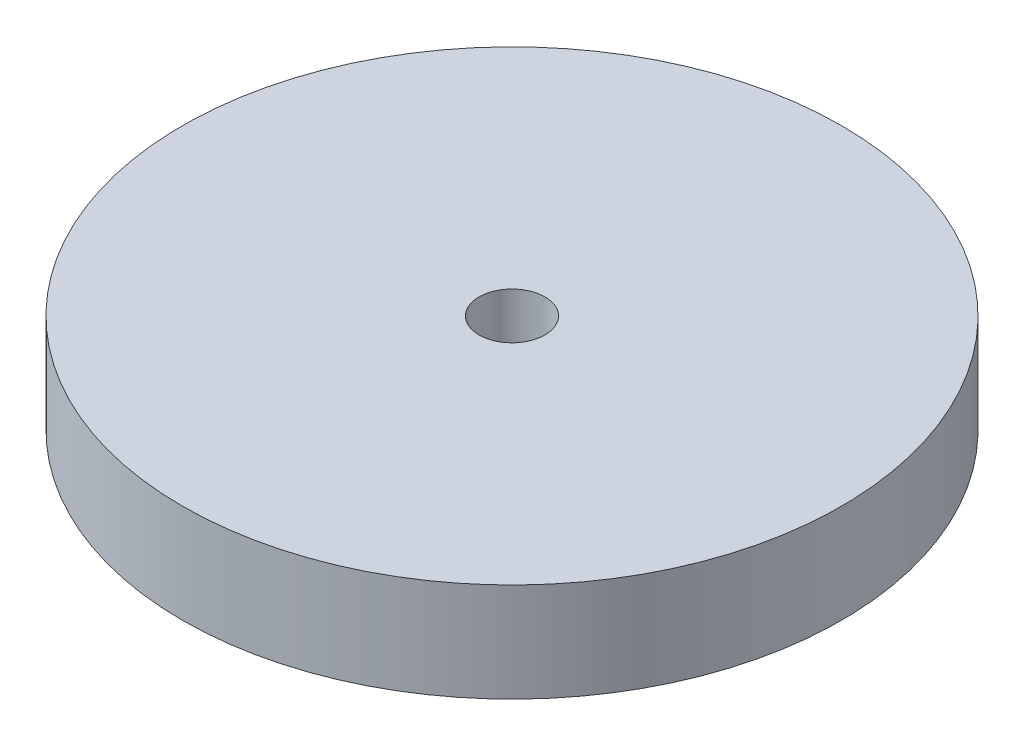
from build123d import *

# Parameters (mm, degrees)
BOSS_EXTRUDE1_DEPTH      = 7.5
BOSS_EXTRUDE1_DEPTH_BACK = 7.5
SKETCH1_R                = 50
CUT_EXTRUDE2_DEPTH       = 72.107313267
CUT_EXTRUDE2_DEPTH_BACK  = 72.107313267
SKETCH2_R                = 5


with BuildPart() as part:
    # Sketch1 → Boss-Extrude1 (new, two sides: drawn at the far end of the back side and taken through both)
    with BuildSketch(Plane(origin=(0, 0, 0), x_dir=(1, 0, 0), z_dir=(0, 1, 0)).offset(-BOSS_EXTRUDE1_DEPTH_BACK)):
        Circle(SKETCH1_R)
    extrude(amount=BOSS_EXTRUDE1_DEPTH + BOSS_EXTRUDE1_DEPTH_BACK)

    # Sketch2 → Cut-Extrude2 (cut, two sides: drawn at the far end of the back side and taken through both)
    with BuildSketch(Plane(origin=(0, 0, 0), x_dir=(1, 0, 0), z_dir=(0, 1, 0)).offset(-CUT_EXTRUDE2_DEPTH_BACK)):
        Circle(SKETCH2_R)
    extrude(amount=CUT_EXTRUDE2_DEPTH + CUT_EXTRUDE2_DEPTH_BACK, mode=Mode.SUBTRACT)


solid = part.part
